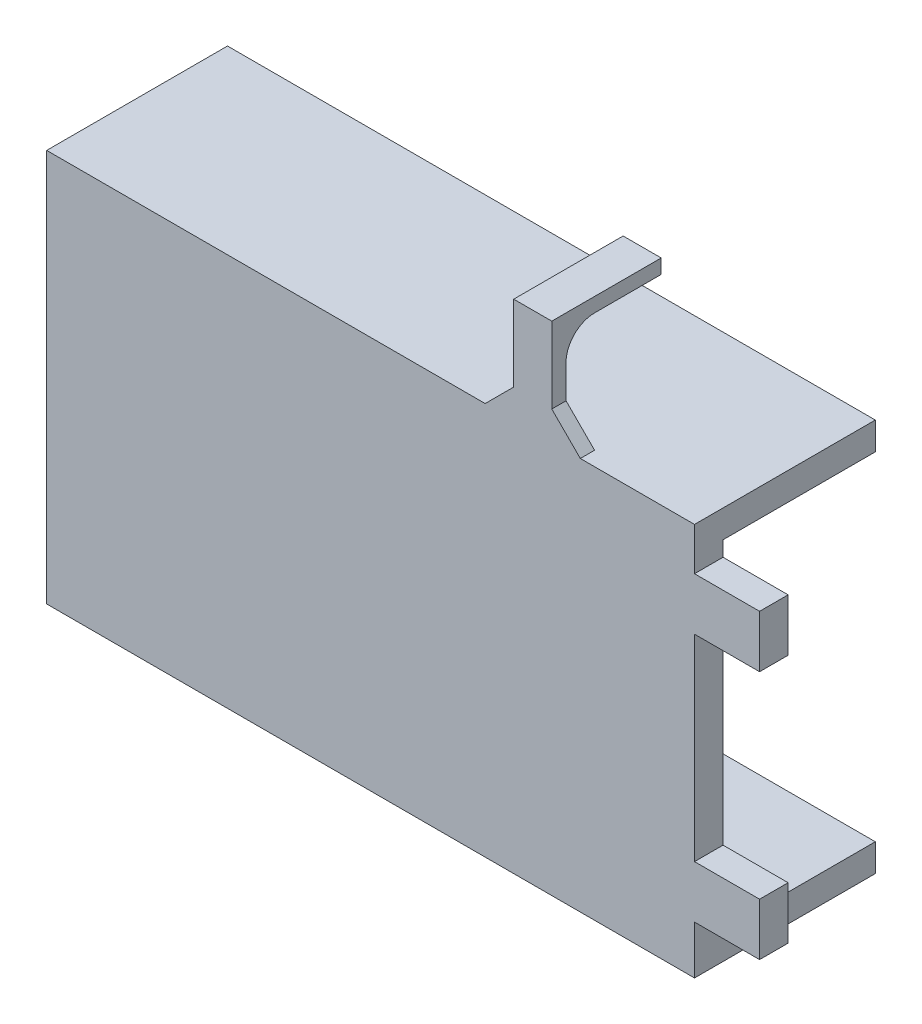
from build123d import *

# Parameters (mm, degrees)
SKETCH_1_W          = 68.077724156
SKETCH_1_H          = 41.280670561
SKETCH_1_W_2        = 62.677724156
SKETCH_1_H_2        = 35.480670561
EXTRUDE_1_DEPTH     = 16
SKETCH_2_W          = 7
SKETCH_2_H          = 13
CUT_EXTRUDE_1_DEPTH = 2.5
SKETCH_3_W          = 16
SKETCH_3_H          = 35.480670561
CUT_EXTRUDE_2_DEPTH = 2.9
SKETCH_4_W          = 68.077724156
SKETCH_4_H          = 41.280670561
EXTRUDE_2_DEPTH     = 3
SKETCH_5_W          = 3
SKETCH_5_H          = 5.5
EXTRUDE_3_DEPTH     = 6.838661
SKETCH_6_W          = 8
SKETCH_6_H          = 15
CUT_EXTRUDE_3_DEPTH = 1
SKETCH_7_W          = 1.5
SKETCH_7_H          = 7
EXTRUDE_4_DEPTH     = 7
SKETCH_8_R          = 1.55
CUT_EXTRUDE_6_DEPTH = 2.5
SKETCH_9_W          = 4
SKETCH_9_H          = 1.5
EXTRUDE_5_DEPTH     = 11
SKETCH_10_W         = 4
SKETCH_10_H         = 1.5
EXTRUDE_6_DEPTH     = 10
CHAMFER_1_SIZE      = 3
FILLET_1_R          = 3
SKETCH_11_W         = 7
SKETCH_11_H         = 1.5
EXTRUDE_7_DEPTH     = 7
SKETCH_12_R         = 1.55
CUT_EXTRUDE_7_DEPTH = 2.5


with BuildPart() as part:
    # 草图1 → 凸台-拉伸1 (new body)
    with BuildSketch(Plane.XY):
        with Locations((-18.003533133, 5.902999581)):
            Rectangle(SKETCH_1_W, SKETCH_1_H)
        with Locations((-18.203533133, 5.902999581)):
            Rectangle(SKETCH_1_W_2, SKETCH_1_H_2, mode=Mode.SUBTRACT)
    extrude(amount=EXTRUDE_1_DEPTH)

    # 草图2 → 切除-拉伸1 (cut)
    with BuildSketch(Plane.ZY.offset(52.042395211)):
        with Locations((3.5, -5.2373357)):
            Rectangle(SKETCH_2_W, SKETCH_2_H)
    extrude(amount=-CUT_EXTRUDE_1_DEPTH, mode=Mode.SUBTRACT)

    # 草图3 → 切除-拉伸2 (cut)
    with BuildSketch(Plane(origin=(16.035328945, 0, 0), x_dir=(0, 0, -1), z_dir=(1, 0, 0))):
        with Locations((-8, 5.902999581)):
            Rectangle(SKETCH_3_W, SKETCH_3_H)
    extrude(amount=-CUT_EXTRUDE_2_DEPTH, mode=Mode.SUBTRACT)

    # 草图4 → 凸台-拉伸2 (add)
    with BuildSketch(Plane.XY.offset(16)):
        with Locations((-18.003533133, 5.902999581)):
            Rectangle(SKETCH_4_W, SKETCH_4_H)
    extrude(amount=EXTRUDE_2_DEPTH)

    # 草图5 → 凸台-拉伸3 (add)
    with BuildSketch(Plane(origin=(16.035328945, 0, 0), x_dir=(0, 0, -1), z_dir=(1, 0, 0))):
        with Locations((-17.5, -6.896027597)):
            Rectangle(SKETCH_5_W, SKETCH_5_H)
        with Locations((-17.5, 19.303972403)):
            Rectangle(SKETCH_5_W, SKETCH_5_H)
    extrude(amount=EXTRUDE_3_DEPTH)

    # 草图6 → 切除-拉伸3 (cut)
    with BuildSketch(Plane.ZY.offset(52.042395211)):
        with Locations((4, -5.2373357)):
            Rectangle(SKETCH_6_W, SKETCH_6_H)
    extrude(amount=-CUT_EXTRUDE_3_DEPTH, mode=Mode.SUBTRACT)

    # 草图7 → 凸台-拉伸4 (add)
    with BuildSketch(Plane.ZY.offset(52.042395211)):
        with Locations((0.75, 15.043334861)):
            Rectangle(SKETCH_7_W, SKETCH_7_H)
    extrude(amount=EXTRUDE_4_DEPTH)

    # 草图8 → 切除-拉伸6 (cut, through all)
    with BuildSketch(Plane.XY.offset(1.5)):
        with Locations((-56.542395211, 15.043334861)):
            Circle(SKETCH_8_R)
    extrude(amount=-CUT_EXTRUDE_6_DEPTH, mode=Mode.SUBTRACT)

    # 草图9 → 凸台-拉伸5 (add)
    with BuildSketch(Plane(origin=(0, 26.543334861, 0), x_dir=(1, 0, 0), z_dir=(0, 1, 0))):
        with Locations((-0.964671055, -18.25)):
            Rectangle(SKETCH_9_W, SKETCH_9_H)
    extrude(amount=EXTRUDE_5_DEPTH)

    # 草图10 → 凸台-拉伸6 (add)
    with BuildSketch(Plane(origin=(0, 0, 17.5), x_dir=(-1, 0, 0), z_dir=(0, 0, -1))):
        with Locations((0.964671055, 36.793334861)):
            Rectangle(SKETCH_10_W, SKETCH_10_H)
    extrude(amount=EXTRUDE_6_DEPTH)

    # 倒角1
    chamfer_1_edges = [part.edges().sort_by_distance(p)[0] for p in [
        (1.035328945, 26.543334861, 18.25),
        (-2.964671055, 26.543334861, 18.25),
    ]]
    chamfer(chamfer_1_edges, length=CHAMFER_1_SIZE)

    # 圆角1
    fillet_1_edges = [part.edges().sort_by_distance(p)[0] for p in [
        (-0.964671055, 36.043334861, 17.5),
    ]]
    fillet(fillet_1_edges, radius=FILLET_1_R)

    # 草图11 → 凸台-拉伸7 (add)
    with BuildSketch(Plane.XZ.offset(14.7373357)):
        with Locations((-17.464671055, 0.75)):
            Rectangle(SKETCH_11_W, SKETCH_11_H)
    extrude(amount=EXTRUDE_7_DEPTH)

    # 草图12 → 切除-拉伸7 (cut, through all)
    with BuildSketch(Plane.XY.offset(1.5)):
        with Locations((-17.464671055, -19.2373357)):
            Circle(SKETCH_12_R)
    extrude(amount=-CUT_EXTRUDE_7_DEPTH, mode=Mode.SUBTRACT)


solid = part.part
